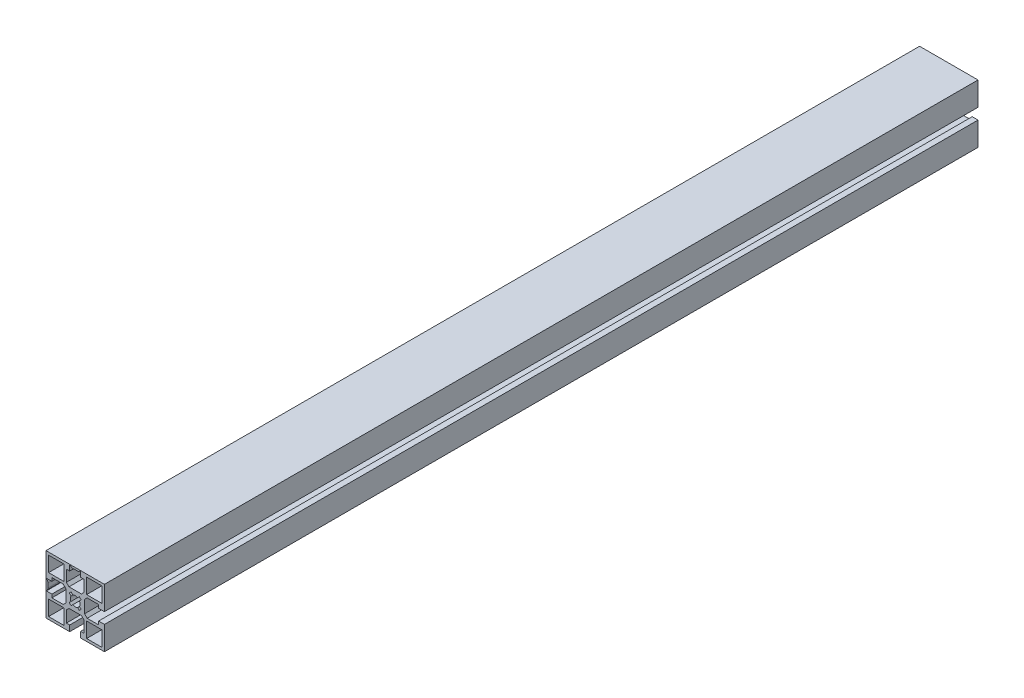
from build123d import *

# Parameters (mm, degrees)
SKETCH1_W           = 11.699975178
SKETCH1_H           = 11.699996949
SKETCH1_W_2         = 11.699990436
SKETCH1_H_2         = 11.699981689
SKETCH1_W_3         = 11.699990437
SKETCH1_H_3         = 11.699975177
SKETCH1_W_4         = 11.699981689
SKETCH1_H_4         = 11.699990436
BOSS_EXTRUDE1_DEPTH = 673.1


with BuildPart() as part:
    # Sketch1 → Boss-Extrude1 (new body)
    with BuildSketch(Plane.XY):
        Polygon((22.500515052, 22.499297556), (-22.499484399, 22.499298105), (-22.499484948, -22.500701346), (-4.249491942, -22.500701568), (-4.249491942, -22.200733242), (-4.24949208, -18.000719999), (-6.799479919, -18.000719999), (-6.799480207, -9.200732353), (-4.799480391, -7.200732362), (4.800525817, -7.200732047), (6.8005258, -9.200731855), (6.800526088, -18.000720263), (4.250507877, -18.000720263), (4.250508015, -22.200733153), (4.250508015, -22.500701672), (22.500514502, -22.500701895), (22.500514725, -4.250714302), (22.200520351, -4.250714302), (18.000507108, -4.25071444), (18.000507108, -6.800702279), (9.200519462, -6.800702567), (7.200519471, -4.800702751), (7.200519156, 4.799303458), (9.200518964, 6.79930344), (18.000507424, 6.799303729), (18.000507424, 4.249285514), (22.200520261, 4.249285652), (22.500514829, 4.249285652), align=None)
        with BuildLine():
            Line((-4.249491247, 17.999291576), (-4.249490956, 22.199304807))
            Line((-4.249490956, 22.199304807), (-3.949472548, 22.199304807))
            Line((-3.949472548, 22.199304807), (-3.481695222, 21.73152644))
            ThreePointArc((-3.481695222, 21.73152644), (-2.670636178, 21.189593132), (-1.713926324, 20.999291428))
            Line((-1.713926324, 20.999291428), (1.714975167, 20.999291428))
            ThreePointArc((1.714975167, 20.999291428), (2.671722509, 21.189608628), (3.482801459, 21.731583767))
            Line((3.482801459, 21.731583767), (3.950490798, 22.199304487))
            Line((3.950490798, 22.199304487), (4.250509108, 22.199304487))
            Line((4.250509108, 22.199304487), (4.250508817, 17.999291575))
            Line((4.250508817, 17.999291575), (6.800527063, 17.999291575))
            Line((6.800527063, 17.999291575), (6.800526453, 9.199302988))
            Line((6.800526453, 9.199302988), (4.800526064, 7.199302969))
            Line((4.800526064, 7.199302969), (-4.799479817, 7.199303635))
            Line((-4.799479817, 7.199303635), (-6.799479854, 9.199304042))
            Line((-6.799479854, 9.199304042), (-6.799479244, 17.999291576))
            Line((-6.799479244, 17.999291576), (-4.249491247, 17.999291576))
        make_face(mode=Mode.SUBTRACT)
        with BuildLine():
            Line((-17.99949762, -4.250714253), (-22.199510799, -4.250714391))
            Line((-22.199510799, -4.250714391), (-22.199510799, -3.950696126))
            Line((-22.199510799, -3.950696126), (-21.731790056, -3.48300681))
            ThreePointArc((-21.731790056, -3.48300681), (-21.189814855, -2.671927844), (-20.999497617, -1.71518046))
            Line((-20.999497617, -1.71518046), (-20.999497617, 1.713721031))
            ThreePointArc((-20.999497617, 1.713721031), (-21.189799286, 2.670430863), (-21.731732544, 3.481489907))
            Line((-21.731732544, 3.481489907), (-22.199510888, 3.949267256))
            Line((-22.199510888, 3.949267256), (-22.199510888, 4.249285566))
            Line((-22.199510888, 4.249285566), (-17.999497356, 4.249285704))
            Line((-17.999497356, 4.249285704), (-17.999497356, 6.79927354))
            Line((-17.999497356, 6.79927354), (-9.199509947, 6.799273828))
            Line((-9.199509947, 6.799273828), (-7.199509956, 4.799274012))
            Line((-7.199509956, 4.799274012), (-7.199509641, -4.800732197))
            Line((-7.199509641, -4.800732197), (-9.199509449, -6.800732179))
            Line((-9.199509449, -6.800732179), (-17.99949762, -6.800732468))
            Line((-17.99949762, -6.800732468), (-17.99949762, -4.250714253))
        make_face(mode=Mode.SUBTRACT)
        with Locations((-14.649542346, -14.650709384)):
            Rectangle(SKETCH1_W, SKETCH1_H, mode=Mode.SUBTRACT)
        with Locations((14.65050626, -14.650767962)):
            Rectangle(SKETCH1_W_2, SKETCH1_H_2, mode=Mode.SUBTRACT)
        with BuildLine():
            Line((-3.181457266, -4.596908447), (-4.595670829, -3.182694885))
            Line((-4.595670829, -3.182694885), (-3.26221457, -1.849238626))
            ThreePointArc((-3.26221457, -1.849238626), (-3.749476751, -0.00071437), (-3.26221457, 1.847809887))
            Line((-3.26221457, 1.847809887), (-4.595670829, 3.181266146))
            Line((-4.595670829, 3.181266146), (-3.181457266, 4.595479708))
            Line((-3.181457266, 4.595479708), (-1.848001007, 3.262023449))
            ThreePointArc((-1.848001007, 3.262023449), (0.000523249, 3.74928563), (1.849047505, 3.262023449))
            Line((1.849047505, 3.262023449), (3.182503764, 4.595479708))
            Line((3.182503764, 4.595479708), (4.596717327, 3.181266146))
            Line((4.596717327, 3.181266146), (3.263261068, 1.847809887))
            ThreePointArc((3.263261068, 1.847809887), (3.750523249, -0.00071437), (3.263261068, -1.849238626))
            Line((3.263261068, -1.849238626), (4.596717327, -3.182694885))
            Line((4.596717327, -3.182694885), (3.182503764, -4.596908447))
            Line((3.182503764, -4.596908447), (1.849047505, -3.263452188))
            ThreePointArc((1.849047505, -3.263452188), (0.000523249, -3.75071437), (-1.848001007, -3.263452188))
            Line((-1.848001007, -3.263452188), (-3.181457266, -4.596908447))
        make_face(mode=Mode.SUBTRACT)
        with Locations((-14.64949028, 14.649335967)):
            Rectangle(SKETCH1_W_3, SKETCH1_H_3, mode=Mode.SUBTRACT)
        with Locations((14.650561583, 14.6492839)):
            Rectangle(SKETCH1_W_4, SKETCH1_H_4, mode=Mode.SUBTRACT)
    extrude(amount=BOSS_EXTRUDE1_DEPTH)


solid = part.part
